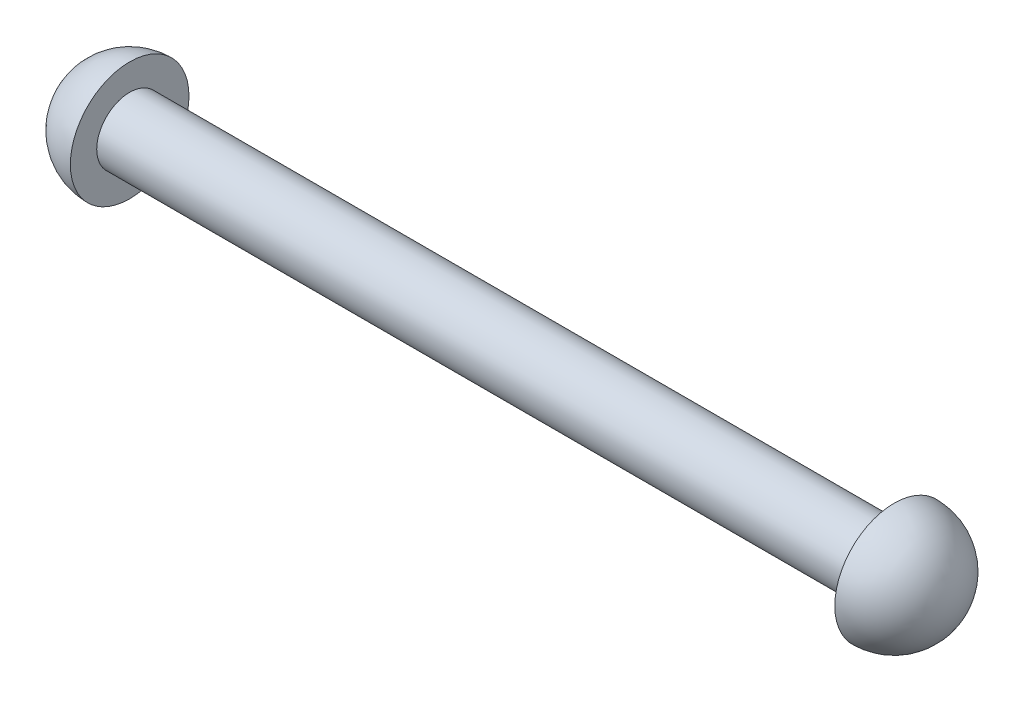
from build123d import *


with BuildPart() as part:
    # Sketch1 → Revolve9 (revolve)
    with BuildSketch(Plane(origin=(0, 0, 0), x_dir=(1, 0, 0), z_dir=(0, 1, 0))):
        with BuildLine():
            Line((-36.83, -5.715), (-36.83, -3.175))
            Line((-36.83, -3.175), (36.83, -3.175))
            Line((36.83, -3.175), (36.83, -5.715))
            ThreePointArc((36.83, -5.715), (40.871115254, -4.041115254), (42.545, 0))
            Line((42.545, 0), (-36.83, 0))
            Line((-36.83, 0), (-42.545, 0))
            ThreePointArc((-42.545, 0), (-40.871115254, -4.041115254), (-36.83, -5.715))
        make_face()
    revolve(axis=Axis((-36.83, 0, 0), (1, 0, 0)))


solid = part.part
